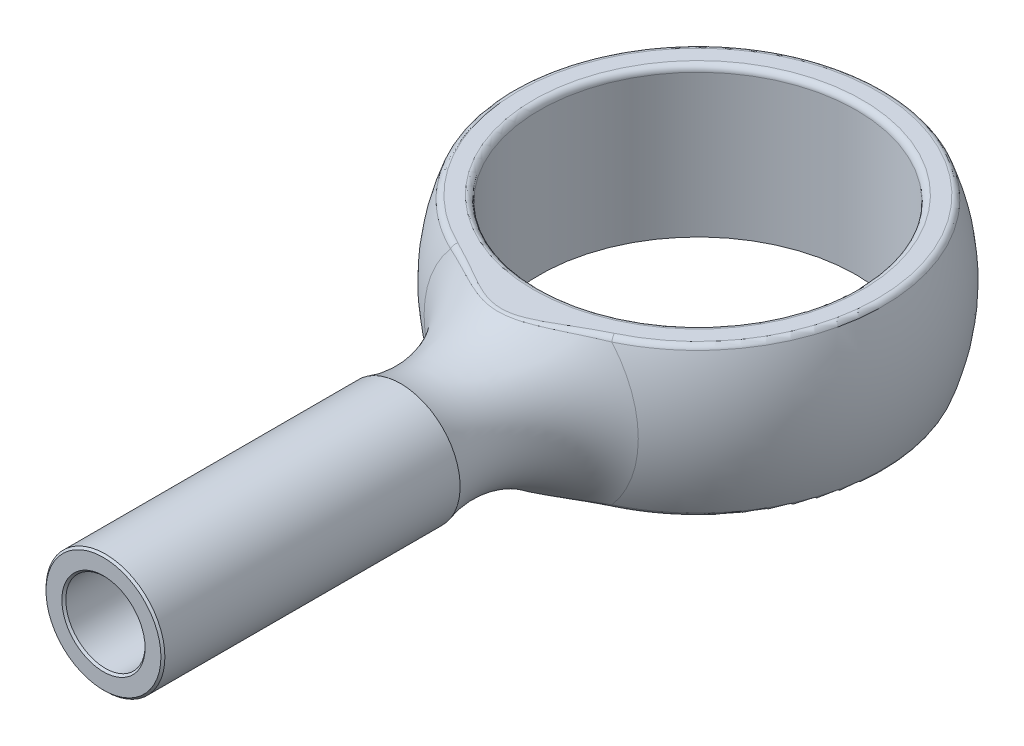
from build123d import *

# Parameters (mm, degrees)
CUT_EXTRUDE1_DEPTH      = 10
CUT_EXTRUDE1_DEPTH_BACK = 10
SKETCH4_R               = 4
CUT_EXTRUDE2_DEPTH      = 10
CUT_EXTRUDE2_DEPTH_BACK = 10
FILLET1_R               = 0.15
SKETCH5_R               = 1
CUT_EXTRUDE3_DEPTH      = 5
CHAMFER1_SIZE           = 0.05


with BuildPart() as part:
    # Sketch2 → Revolve1 (revolve)
    with BuildSketch(Plane(origin=(0, 0, 0), x_dir=(1, 0, 0), z_dir=(0, 1, 0))):
        with BuildLine():
            Line((-1.5, -15), (0, -15))
            Line((0, -15), (0, 5))
            ThreePointArc((0, 5), (-4.79758973, 1.408237475), (-2.702458258, -4.206746886))
            ThreePointArc((-2.702458258, -4.206746886), (-1.546688632, -5.650895292), (-1.5, -7.5))
            Line((-1.5, -7.5), (-1.5, -15))
        make_face()
    revolve(axis=Axis((0, 0, -5), (0, 0, 1)))

    # Sketch3 → Cut-Extrude1 (cut, two sides)
    with BuildSketch(Plane(origin=(0, 0, 0), x_dir=(0, 0, -1), z_dir=(1, 0, 0))) as cut_extrude1_sk:
        with BuildLine():
            Line((-17.836706107, 9.431664346), (9.515900439, 9.431664346))
            Line((9.515900439, 9.431664346), (9.515900439, 1.875))
            Line((9.515900439, 1.875), (-5.468177039, 1.875))
            ThreePointArc((-5.468177039, 1.875), (-6.971706036, 2.106415246), (-8.336059221, 2.779239779))
            Line((-8.336059221, 2.779239779), (-17.836706107, 9.431664346))
        make_face()
        with BuildLine():
            Line((9.515900439, -1.875), (-5.468177039, -1.875))
            ThreePointArc((-5.468177039, -1.875), (-6.971706036, -2.106415246), (-8.336059221, -2.779239779))
            Line((-8.336059221, -2.779239779), (-17.836706107, -9.431664346))
            Line((-17.836706107, -9.431664346), (9.515900439, -9.431664346))
            Line((9.515900439, -9.431664346), (9.515900439, -1.875))
        make_face()
    extrude(amount=CUT_EXTRUDE1_DEPTH, mode=Mode.SUBTRACT)
    extrude(cut_extrude1_sk.sketch, amount=-CUT_EXTRUDE1_DEPTH_BACK, mode=Mode.SUBTRACT)

    # Sketch4 → Cut-Extrude2 (cut, two sides)
    with BuildSketch(Plane(origin=(0, 0, 0), x_dir=(1, 0, 0), z_dir=(0, 1, 0))) as cut_extrude2_sk:
        Circle(SKETCH4_R)
    extrude(amount=CUT_EXTRUDE2_DEPTH, mode=Mode.SUBTRACT)
    extrude(cut_extrude2_sk.sketch, amount=-CUT_EXTRUDE2_DEPTH_BACK, mode=Mode.SUBTRACT)

    # Fillet1
    fillet1_edges = [part.edges().sort_by_distance(p)[0] for p in [
        (0, 1.875, -4.635124054),
        (0, -1.875, -4.635124054),
        (-4, 1.875, 0),
    ]]
    fillet(fillet1_edges, radius=FILLET1_R)

    # Sketch5 → Cut-Extrude3 (cut)
    with BuildSketch(Plane.XY.offset(15)):
        Circle(SKETCH5_R)
    extrude(amount=-CUT_EXTRUDE3_DEPTH, mode=Mode.SUBTRACT)

    # Chamfer1
    chamfer1_edges = [part.edges().sort_by_distance(p)[0] for p in [
        (1.5, 0, 15),
        (-1, 0, 15),
    ]]
    chamfer(chamfer1_edges, length=CHAMFER1_SIZE)


solid = part.part
